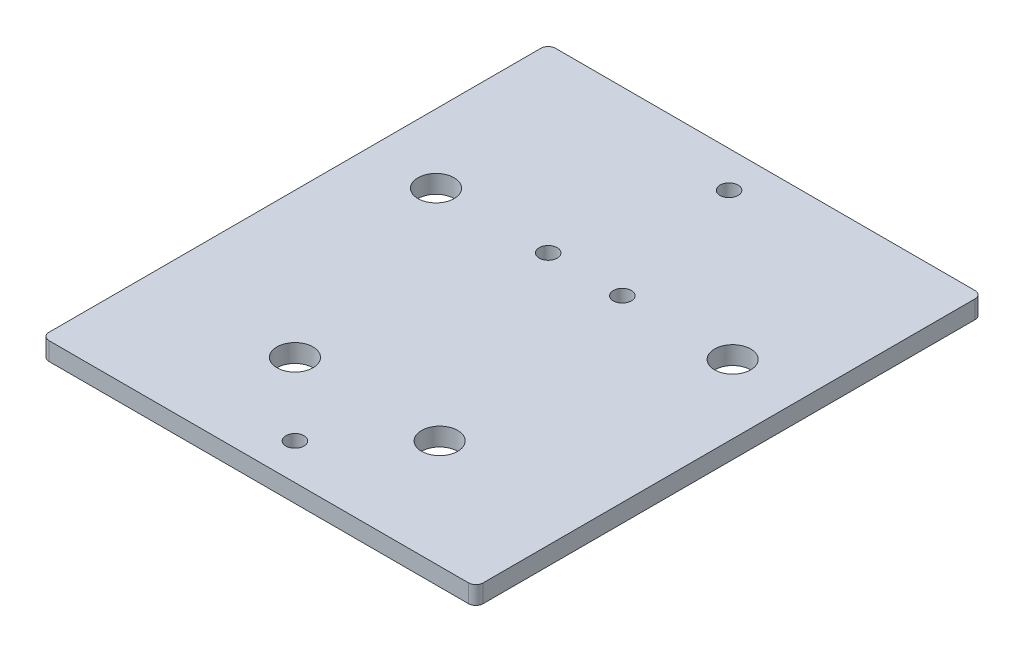
from build123d import *

# Parameters (mm, degrees)
SKETCH1_W           = 152.4
SKETCH1_H           = 177.8
SKETCH1_R           = 6.35
SKETCH1_R_2         = 3.175
BOSS_EXTRUDE1_DEPTH = 6.35
FILLET1_R           = 2.54


with BuildPart() as part:
    # Sketch1 → Boss-Extrude1 (new body)
    with BuildSketch(Plane(origin=(0, 0, 0), x_dir=(1, 0, 0), z_dir=(0, 1, 0))):
        with Locations((76.2, 88.9)):
            Rectangle(SKETCH1_W, SKETCH1_H)
        with Locations((24.13, 114.3)):
            Circle(SKETCH1_R, mode=Mode.SUBTRACT)
        with Locations((128.27, 114.3)):
            Circle(SKETCH1_R, mode=Mode.SUBTRACT)
        with Locations((50.8, 38.1)):
            Circle(SKETCH1_R, mode=Mode.SUBTRACT)
        with Locations((101.6, 38.1)):
            Circle(SKETCH1_R, mode=Mode.SUBTRACT)
        with Locations((76.2, 165.1)):
            Circle(SKETCH1_R_2, mode=Mode.SUBTRACT)
        with Locations((76.2, 12.7)):
            Circle(SKETCH1_R_2, mode=Mode.SUBTRACT)
        with Locations((63.5, 114.3)):
            Circle(SKETCH1_R_2, mode=Mode.SUBTRACT)
        with Locations((89.535, 114.3)):
            Circle(SKETCH1_R_2, mode=Mode.SUBTRACT)
    extrude(amount=BOSS_EXTRUDE1_DEPTH)

    # Fillet1
    fillet1_edges = [part.edges().sort_by_distance(p)[0] for p in [
        (0, 3.175, -177.8),
        (152.4, 3.175, -177.8),
        (152.4, 3.175, 0),
        (0, 3.175, 0),
    ]]
    fillet(fillet1_edges, radius=FILLET1_R)


solid = part.part
